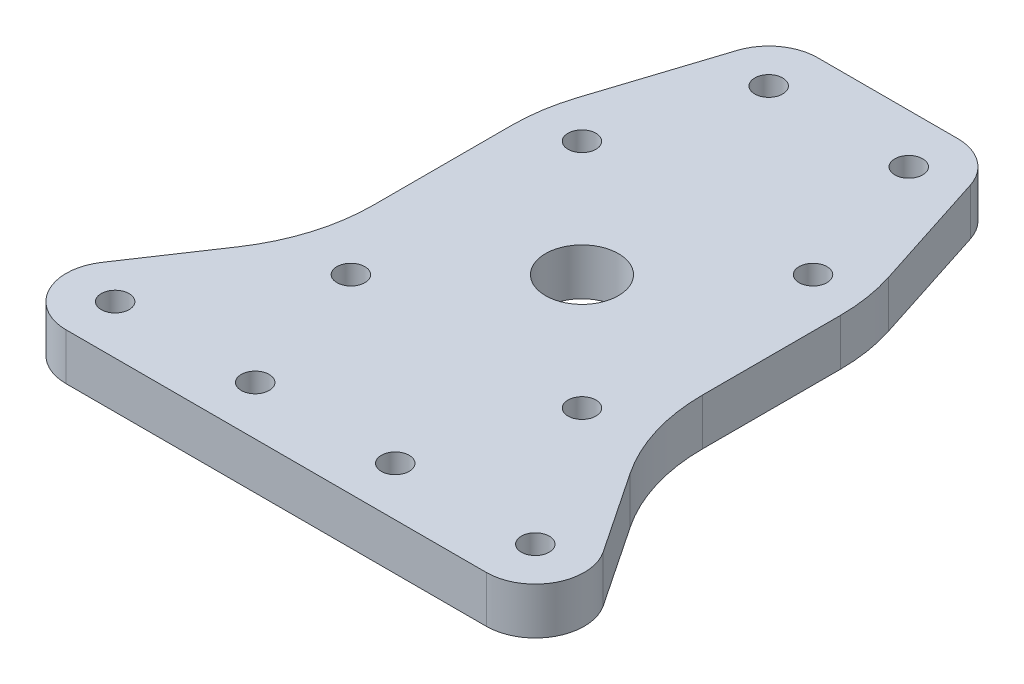
from build123d import *

# Parameters (mm, degrees)
BOSS_EXTRUDE1_DEPTH       = 6.35
F_6_CLEARANCE_HOLE1_D     = 3.7973
FILLET1_R                 = 17.78
F_7_16_20_TAPPED_HOLE1_D  = 9.92124
F_6_CLEARANCE_HOLE2_D     = 3.7973
F_6_CLEARANCE_HOLE2_DEPTH = 6.35
CUT_EXTRUDE1_DEPTH        = 7.35
FILLET2_R                 = 25.4


with BuildPart() as part:
    # Sketch1 → Boss-Extrude1 (new body)
    with BuildSketch(Plane(origin=(0, 0, 0), x_dir=(1, 0, 0), z_dir=(0, 1, 0))):
        Polygon((-57.15, 0), (0, 114.3), (57.15, 0), align=None)
    extrude(amount=-BOSS_EXTRUDE1_DEPTH)

    # #6 Clearance Hole1 (through all)
    with Locations(Plane(origin=(0, 0, 0), x_dir=(1, 0, 0), z_dir=(0, 1, 0))):
        with Locations((28.575, 9.525), (9.525, 9.525), (-9.525, 79.375), (9.525, 79.375), (-28.575, 9.525), (-9.525, 9.525)):
            Hole(F_6_CLEARANCE_HOLE1_D / 2)

    # Fillet1
    fillet1_edges = [part.edges().sort_by_distance(p)[0] for p in [
        (-57.15, -3.175, 0),
        (0, -3.175, -114.3),
        (57.15, -3.175, 0),
    ]]
    fillet(fillet1_edges, radius=FILLET1_R)

    # 7/16-20 Tapped Hole1 (through all)
    with Locations(Plane(origin=(0, 0, 0), x_dir=(1, 0, 0), z_dir=(0, 1, 0))):
        with Locations((0, 44.45)):
            Hole(F_7_16_20_TAPPED_HOLE1_D / 2)

    # #6 Clearance Hole2
    with Locations(Plane(origin=(0, 0, 0), x_dir=(1, 0, 0), z_dir=(0, 1, 0))):
        with Locations((-15.715448212, 60.165448212), (15.715448212, 28.734551788), (-15.715448212, 28.734551788), (15.715448212, 60.165448212)):
            Hole(F_6_CLEARANCE_HOLE2_D / 2, depth=F_6_CLEARANCE_HOLE2_DEPTH)

    # Sketch9 → Cut-Extrude1 (cut, through all)
    with BuildSketch(Plane(origin=(0, 0, 0), x_dir=(1, 0, 0), z_dir=(0, 1, 0))):
        with BuildLine():
            ThreePointArc((15.902915456, 82.494169088), (0, 92.32271136), (-15.902915456, 82.494169088))
            Line((-15.902915456, 82.494169088), (-44.284271136, 25.731457728))
            ThreePointArc((-44.284271136, 25.731457728), (-43.505927053, 8.432500827), (-28.38135568, 0))
            Line((-28.38135568, 0), (28.38135568, 0))
            ThreePointArc((28.38135568, 0), (43.505927053, 8.432500827), (44.284271136, 25.731457728))
            Line((44.284271136, 25.731457728), (15.902915456, 82.494169088))
        make_face()
        with BuildLine():
            Line((-22.376598212, 60.165448212), (-22.376598212, 61.212248927))
            Line((-22.376598212, 61.212248927), (-22.055517914, 62.208591744))
            Line((-22.055517914, 62.208591744), (-15.865069677, 81.41814361))
            ThreePointArc((-15.865069677, 81.41814361), (-13.446812927, 84.759264359), (-9.525, 86.03615))
            Line((-9.525, 86.03615), (9.525, 86.03615))
            ThreePointArc((9.525, 86.03615), (13.446812927, 84.759264359), (15.865069677, 81.41814361))
            Line((15.865069677, 81.41814361), (22.055518291, 62.208590573))
            Line((22.055518291, 62.208590573), (22.376598212, 61.212248927))
            Line((22.376598212, 61.212248927), (22.376598212, 60.165448212))
            Line((22.376598212, 60.165448212), (22.376598212, 30.758347904))
            Line((22.376598212, 30.758347904), (34.110328487, 13.230544207))
            ThreePointArc((34.110328487, 13.230544207), (34.948483062, 11.461396908), (35.23615, 9.525))
            ThreePointArc((35.23615, 9.525), (33.285144336, 4.814855664), (28.575, 2.86385))
            Line((28.575, 2.86385), (9.525000022, 2.86385))
            Line((9.525000022, 2.86385), (-9.525, 2.86385))
            Line((-9.525, 2.86385), (-28.575, 2.86385))
            ThreePointArc((-28.575, 2.86385), (-34.450972478, 6.387506292), (-34.110328487, 13.230544207))
            Line((-34.110328487, 13.230544207), (-22.376598212, 30.758347904))
            Line((-22.376598212, 30.758347904), (-22.376598212, 60.165448212))
        make_face(mode=Mode.SUBTRACT)
    extrude(amount=-CUT_EXTRUDE1_DEPTH, mode=Mode.SUBTRACT)

    # Fillet2
    fillet2_edges = [part.edges().sort_by_distance(p)[0] for p in [
        (22.376598212, -3.175, -30.758347904),
        (22.376598212, -3.175, -61.212248927),
        (-22.376598212, -3.175, -61.212248927),
        (-22.376598212, -3.175, -30.758347904),
    ]]
    fillet(fillet2_edges, radius=FILLET2_R)


solid = part.part
